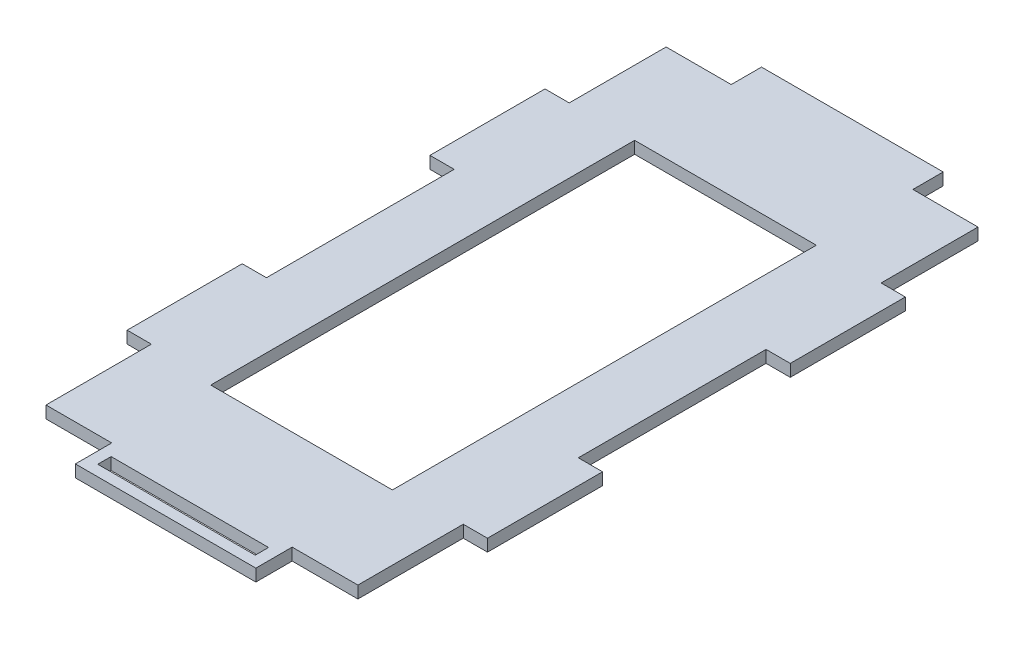
from build123d import *

# Parameters (mm, degrees)
AUFSATZ_LINEAR_AUSTRAGEN2_DEPTH = 2
SKIZZE4_W                       = 30
SKIZZE4_H                       = 70
SKIZZE4_W_2                     = 26
SKIZZE4_H_2                     = 2.2
SCHNITT_LINEAR_AUSTRAGEN1_DEPTH = 2


with BuildPart() as part:
    # Skizze3 → Aufsatz-Linear austragen2 (new body)
    with BuildSketch(Plane(origin=(0, 0, 0), x_dir=(1, 0, 0), z_dir=(0, 1, 0))):
        Polygon((-29.8, 0), (0, 0), (0, 6), (10.85, 6), (10.85, 23.4), (14.85, 23.4), (14.85, 42.4), (10.85, 42.4), (10.85, 73.4), (14.85, 73.4), (14.85, 92.4), (10.85, 92.4), (10.85, 108.4), (0.1, 108.4), (0.1, 113.4), (-29.9, 113.4), (-29.9, 108.4), (-40.65, 108.4), (-40.65, 92.4), (-44.65, 92.4), (-44.65, 73.4), (-40.65, 73.4), (-40.65, 42.4), (-44.65, 42.4), (-44.65, 23.4), (-40.65, 23.4), (-40.65, 6), (-29.8, 6), align=None)
    extrude(amount=AUFSATZ_LINEAR_AUSTRAGEN2_DEPTH)

    # Skizze4 → Schnitt-Linear austragen1 (cut)
    with BuildSketch(Plane(origin=(0, 2, 0), x_dir=(1, 0, 0), z_dir=(0, 1, 0))):
        with Locations((-14.9, 57.449848024)):
            Rectangle(SKIZZE4_W, SKIZZE4_H)
        with Locations((-14.9, 2.9)):
            Rectangle(SKIZZE4_W_2, SKIZZE4_H_2)
    extrude(amount=-SCHNITT_LINEAR_AUSTRAGEN1_DEPTH, mode=Mode.SUBTRACT)


solid = part.part
